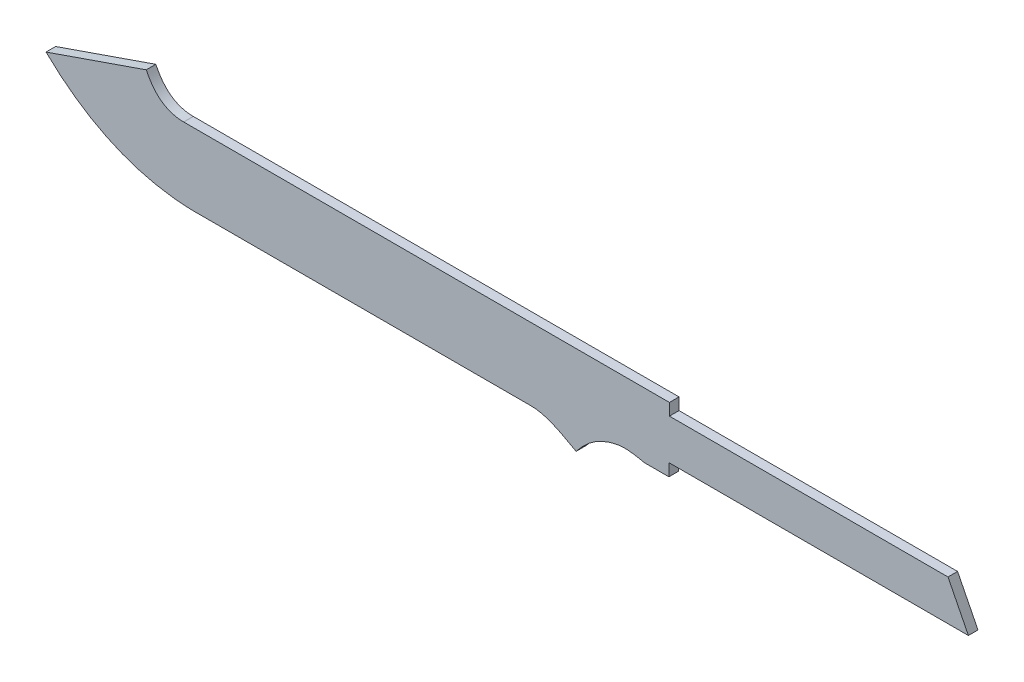
from build123d import *

# Parameters (mm, degrees)
AUFSATZ_LINEAR_AUSTRAGEN1_DEPTH = 3.5


with BuildPart() as part:
    # Skizze1 → Aufsatz-Linear austragen1 (new body, symmetric)
    with BuildSketch(Plane.XY):
        with BuildLine():
            Line((831.647452371, 366.448530177), (628.572821229, 366.448530177))
            Line((628.572821229, 366.448530177), (628.572821229, 375.106989994))
            Line((628.572821229, 375.106989994), (274.428895499, 375.106989994))
            add(Edge.make_bspline(
                [(274.428895499, 375.106989994), (256.358547924, 375.106989994), (247.122592497, 394.383569374)],
                knots=[0, 0, 0, 1, 1, 1], degree=2))
            Line((247.122592497, 394.383569374), (174.038075638, 369.085082769))
            add(Edge.make_bspline(
                [(174.038075638, 369.085082769), (207.417770849, 336.709288166), (244.126187853, 323.555937748), (280.251563051, 322.503742353)],
                knots=[0, 0, 0, 0, 1, 1, 1, 1], degree=3))
            Line((280.251563051, 322.503742353), (527.843524378, 322.503742353))
            add(Edge.make_bspline(
                [(527.843524378, 322.503742353), (541.993033664, 322.503742353), (557.358077917, 311.262922103), (560.616559045, 310.285377764)],
                knots=[0, 0, 0, 0, 1, 1, 1, 1], degree=3))
            add(Edge.make_bspline(
                [(560.616559045, 310.285377764), (569.016239065, 321.364266067), (579.47275725, 327.823555694), (591.986113601, 329.663246645)],
                knots=[0, 0, 0, 0, 1, 1, 1, 1], degree=3))
            add(Edge.make_bspline(
                [(591.986113601, 329.663246645), (599.533888677, 330.772906845), (610.017065826, 327.93253872), (610.038691557, 327.93253872)],
                knots=[0, 0, 0, 0, 1, 1, 1, 1], degree=3))
            Line((610.038691557, 327.93253872), (628.174793789, 327.93253872))
            Line((628.174793789, 327.93253872), (628.174793789, 336.911119919))
            Line((628.174793789, 336.911119919), (846.52672127, 336.911119919))
            Line((846.52672127, 336.911119919), (831.647452371, 366.448530177))
        make_face()
    extrude(amount=AUFSATZ_LINEAR_AUSTRAGEN1_DEPTH, both=True)


solid = part.part
